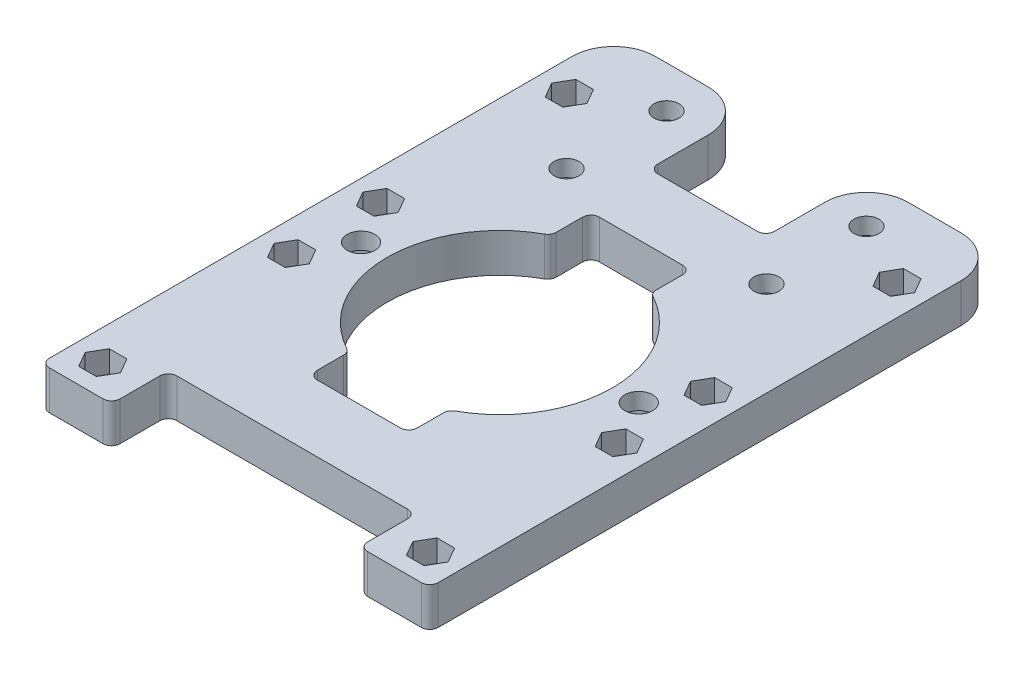
from build123d import *

# Parameters (mm, degrees)
SKETCH1_R           = 2.25
SKETCH1_R_2         = 2.5
BOSS_EXTRUDE1_DEPTH = 7
CUT_EXTRUDE1_DEPTH  = 4
CUT_EXTRUDE2_DEPTH  = 4
CUT_EXTRUDE3_DEPTH  = 4


with BuildPart() as part:
    # Sketch1 → Boss-Extrude1 (new body)
    with BuildSketch(Plane(origin=(0, 0, 0), x_dir=(1, 0, 0), z_dir=(0, 1, 0))):
        with BuildLine():
            Line((-35, 48), (-35, -46.101))
            ThreePointArc((-35, -46.101), (-34.553630735, -47.178630735), (-33.476, -47.625))
            Line((-33.476, -47.625), (-23.824, -47.625))
            ThreePointArc((-23.824, -47.625), (-22.746369265, -47.178630735), (-22.3, -46.101))
            Line((-22.3, -46.101), (-22.3, -38.924))
            ThreePointArc((-22.3, -38.924), (-21.853630735, -37.846369265), (-20.776, -37.4))
            Line((-20.776, -37.4), (20.776, -37.4))
            ThreePointArc((20.776, -37.4), (21.853630735, -37.846369265), (22.3, -38.924))
            Line((22.3, -38.924), (22.3, -46.101))
            ThreePointArc((22.3, -46.101), (22.746369265, -47.178630735), (23.824, -47.625))
            Line((23.824, -47.625), (33.476, -47.625))
            ThreePointArc((33.476, -47.625), (34.553630735, -47.178630735), (35, -46.101))
            Line((35, -46.101), (35, 48))
            ThreePointArc((35, 48), (32.803300859, 53.303300859), (27.5, 55.5))
            Line((27.5, 55.5), (18, 55.5))
            ThreePointArc((18, 55.5), (12.696699141, 53.303300859), (10.5, 48))
            Line((10.5, 48), (10.5, 38.924))
            ThreePointArc((10.5, 38.924), (10.053630735, 37.846369265), (8.976, 37.4))
            Line((8.976, 37.4), (-8.976, 37.4))
            ThreePointArc((-8.976, 37.4), (-10.053630735, 37.846369265), (-10.5, 38.924))
            Line((-10.5, 38.924), (-10.5, 48))
            ThreePointArc((-10.5, 48), (-12.696699141, 53.303300859), (-18, 55.5))
            Line((-18, 55.5), (-27.5, 55.5))
            ThreePointArc((-27.5, 55.5), (-32.803300859, 53.303300859), (-35, 48))
        make_face()
        with Locations(Location((-18, 48, 0), (0, 0, 270))):  # turned: the seam where the file's is
            Circle(SKETCH1_R, mode=Mode.SUBTRACT)
        with Locations(Location((18, 48, 0), (0, 0, 270))):  # turned: the seam where the file's is
            Circle(SKETCH1_R, mode=Mode.SUBTRACT)
        with Locations(Location((-18, 30, 0), (0, 0, 270))):  # turned: the seam where the file's is
            Circle(SKETCH1_R, mode=Mode.SUBTRACT)
        with Locations(Location((18, 30, 0), (0, 0, 270))):  # turned: the seam where the file's is
            Circle(SKETCH1_R, mode=Mode.SUBTRACT)
        with Locations(Location((-29.5, 42, 0), (0, 0, 270))):  # turned: the seam where the file's is
            Circle(SKETCH1_R, mode=Mode.SUBTRACT)
        with Locations(Location((-29.5, 8, 0), (0, 0, 270))):  # turned: the seam where the file's is
            Circle(SKETCH1_R, mode=Mode.SUBTRACT)
        with Locations(Location((-29.5, -8, 0), (0, 0, 270))):  # turned: the seam where the file's is
            Circle(SKETCH1_R, mode=Mode.SUBTRACT)
        with Locations(Location((-29.5, -42, 0), (0, 0, 270))):  # turned: the seam where the file's is
            Circle(SKETCH1_R, mode=Mode.SUBTRACT)
        with Locations(Location((29.5, -8, 0), (0, 0, 270))):  # turned: the seam where the file's is
            Circle(SKETCH1_R, mode=Mode.SUBTRACT)
        with Locations(Location((29.5, -42, 0), (0, 0, 270))):  # turned: the seam where the file's is
            Circle(SKETCH1_R, mode=Mode.SUBTRACT)
        with Locations(Location((29.5, 42, 0), (0, 0, 270))):  # turned: the seam where the file's is
            Circle(SKETCH1_R, mode=Mode.SUBTRACT)
        with Locations(Location((29.5, 8, 0), (0, 0, 270))):  # turned: the seam where the file's is
            Circle(SKETCH1_R, mode=Mode.SUBTRACT)
        with Locations(Location((-25, 0, 0), (0, 0, 270))):  # turned: the seam where the file's is
            Circle(SKETCH1_R_2, mode=Mode.SUBTRACT)
        with Locations(Location((25, 0, 0), (0, 0, 270))):  # turned: the seam where the file's is
            Circle(SKETCH1_R_2, mode=Mode.SUBTRACT)
        with BuildLine():
            Line((-9, -19.14172824), (-9, -23.876))
            ThreePointArc((-9, -23.876), (-8.553630735, -24.953630735), (-7.476, -25.4))
            Line((-7.476, -25.4), (7.476, -25.4))
            ThreePointArc((7.476, -25.4), (8.553630735, -24.953630735), (9, -23.876))
            Line((9, -23.876), (9, -19.14172824))
            ThreePointArc((9, -19.14172824), (9.212217545, -18.365968747), (9.789767442, -17.806258828))
            ThreePointArc((9.789767442, -17.806258828), (20.32, 0), (9.789767442, 17.806258828))
            ThreePointArc((9.789767442, 17.806258828), (9.212217545, 18.365968747), (9, 19.14172824))
            Line((9, 19.14172824), (9, 23.876))
            ThreePointArc((9, 23.876), (8.553630735, 24.953630735), (7.476, 25.4))
            Line((7.476, 25.4), (-7.476, 25.4))
            ThreePointArc((-7.476, 25.4), (-8.553630735, 24.953630735), (-9, 23.876))
            Line((-9, 23.876), (-9, 19.14172824))
            ThreePointArc((-9, 19.14172824), (-9.212217545, 18.365968747), (-9.789767442, 17.806258828))
            ThreePointArc((-9.789767442, 17.806258828), (-20.32, 0), (-9.789767442, -17.806258828))
            ThreePointArc((-9.789767442, -17.806258828), (-9.212217545, -18.365968747), (-9, -19.14172824))
        make_face(mode=Mode.SUBTRACT)
    extrude(amount=BOSS_EXTRUDE1_DEPTH)

    # Sketch2 → Cut-Extrude1 (cut)
    with BuildSketch(Plane(origin=(0, 7, 0), x_dir=(1, 0, 0), z_dir=(0, 1, 0))):
        Polygon((-26.324573519, 42), (-27.91228676, 44.75), (-31.08771324, 44.75), (-32.675426481, 42), (-31.08771324, 39.25), (-27.91228676, 39.25), align=None)
        Polygon((26.324573519, 42), (27.91228676, 39.25), (31.08771324, 39.25), (32.675426481, 42), (31.08771324, 44.75), (27.91228676, 44.75), align=None)
        Polygon((26.324573519, 8), (27.91228676, 5.25), (31.08771324, 5.25), (32.675426481, 8), (31.08771324, 10.75), (27.91228676, 10.75), align=None)
        Polygon((26.324573519, -8), (27.91228676, -10.75), (31.08771324, -10.75), (32.675426481, -8), (31.08771324, -5.25), (27.91228676, -5.25), align=None)
        Polygon((26.324573519, -42), (27.91228676, -44.75), (31.08771324, -44.75), (32.675426481, -42), (31.08771324, -39.25), (27.91228676, -39.25), align=None)
        Polygon((-26.324573519, -42), (-27.91228676, -39.25), (-31.08771324, -39.25), (-32.675426481, -42), (-31.08771324, -44.75), (-27.91228676, -44.75), align=None)
        Polygon((-26.324573519, -8), (-27.91228676, -5.25), (-31.08771324, -5.25), (-32.675426481, -8), (-31.08771324, -10.75), (-27.91228676, -10.75), align=None)
        Polygon((-26.324573519, 8), (-27.91228676, 10.75), (-31.08771324, 10.75), (-32.675426481, 8), (-31.08771324, 5.25), (-27.91228676, 5.25), align=None)
    extrude(amount=-CUT_EXTRUDE1_DEPTH, mode=Mode.SUBTRACT)

    # Sketch3 → Cut-Extrude2 (cut)
    with BuildSketch(Plane.XZ):
        Polygon((-18, -33.175426481), (-15.25, -31.58771324), (-15.25, -28.41228676), (-18, -26.824573519), (-20.75, -28.41228676), (-20.75, -31.58771324), align=None)
        Polygon((-18, -51.175426481), (-15.25, -49.58771324), (-15.25, -46.41228676), (-18, -44.824573519), (-20.75, -46.41228676), (-20.75, -49.58771324), align=None)
        Polygon((18, -51.175426481), (20.75, -49.58771324), (20.75, -46.41228676), (18, -44.824573519), (15.25, -46.41228676), (15.25, -49.58771324), align=None)
        Polygon((18, -33.175426481), (20.75, -31.58771324), (20.75, -28.41228676), (18, -26.824573519), (15.25, -28.41228676), (15.25, -31.58771324), align=None)
    extrude(amount=-CUT_EXTRUDE2_DEPTH, mode=Mode.SUBTRACT)

    # Sketch4 → Cut-Extrude3 (cut)
    with BuildSketch(Plane.XZ):
        Polygon((-25, -4.330127019), (-21.25, -2.165063509), (-21.25, 2.165063509), (-25, 4.330127019), (-28.75, 2.165063509), (-28.75, -2.165063509), align=None)
        Polygon((25, -4.330127019), (28.75, -2.165063509), (28.75, 2.165063509), (25, 4.330127019), (21.25, 2.165063509), (21.25, -2.165063509), align=None)
    extrude(amount=-CUT_EXTRUDE3_DEPTH, mode=Mode.SUBTRACT)


solid = part.part
